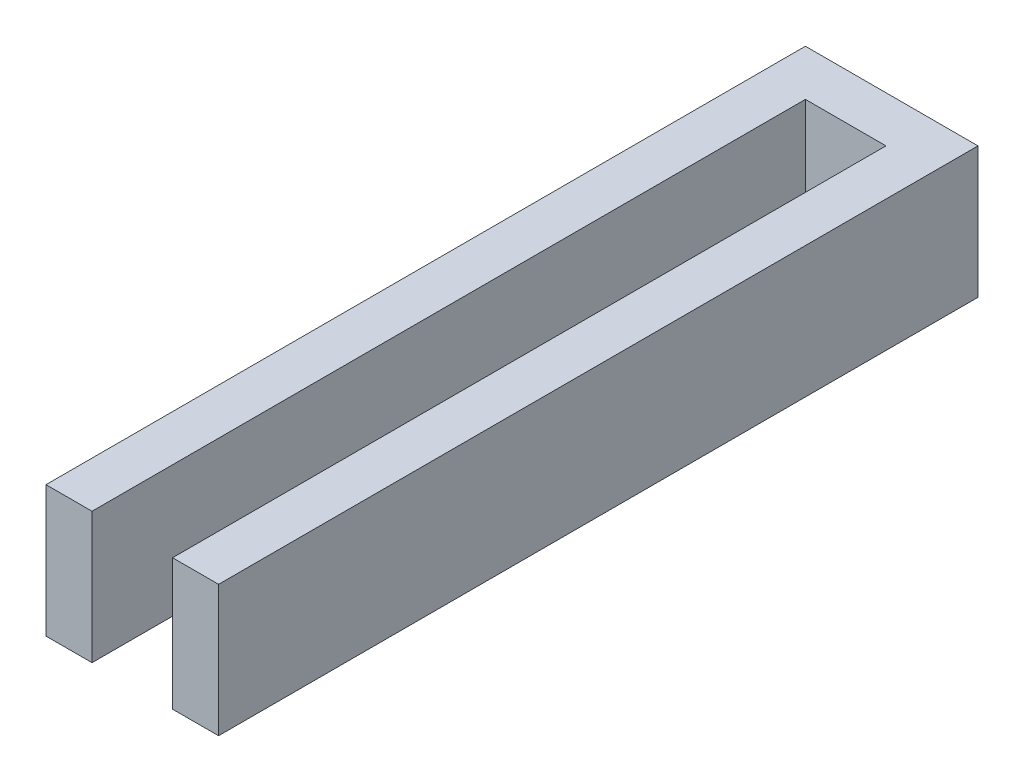
from build123d import *

# Parameters (mm, degrees)
SALIENTE_EXTRUIR1_DEPTH = 5.7


with BuildPart() as part:
    # Croquis1 → Saliente-Extruir1 (new body)
    with BuildSketch(Plane(origin=(0, 0, 0), x_dir=(1, 0, 0), z_dir=(0, 1, 0))):
        Polygon((8.512152778, 14.539930556), (1.012152778, 14.539930556), (1.012152778, -18.460069444), (3.012152778, -18.460069444), (3.012152778, 12.539930556), (6.512152778, 12.539930556), (6.512152778, -18.460069444), (8.512152778, -18.460069444), align=None)
    extrude(amount=SALIENTE_EXTRUIR1_DEPTH)


solid = part.part
